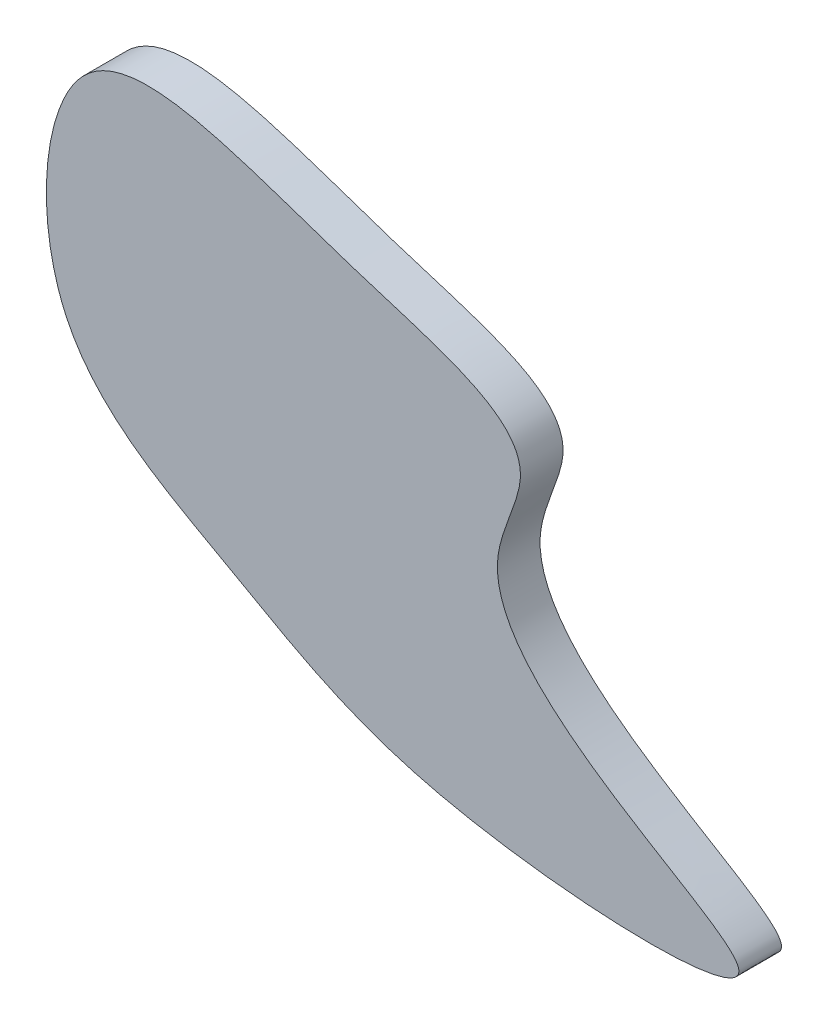
from build123d import *

# Parameters (mm, degrees)
AUFSATZ_LINEAR_AUSTRAGEN1_DEPTH = 10


with BuildPart() as part:
    # Skizze1 → Aufsatz-Linear austragen1 (new body)
    with BuildSketch(Plane.XY):
        with BuildLine():
            add(Edge.make_bspline(
                [(-80.538228006, 16.11258968), (-73.222394057, 0.474519064), (-39.773783933, -16.204726599), (0.660761159, -42.279815022), (127.962480816, -47.405838525), (3.664983183, -3.73898255), (35.35770239, 46.696284543), (-22.525997246, 60.021411727), (-83.548915587, 88.845318161), (-88.209584535, 32.510612923), (-80.538228006, 16.11258968)],
                knots=[0, 0, 0, 0, 0.112755714, 0.233476145, 0.401323458, 0.583683402, 0.629662187, 0.7307253, 0.881764774, 1, 1, 1, 1], degree=3))
        make_face()
    extrude(amount=AUFSATZ_LINEAR_AUSTRAGEN1_DEPTH)


solid = part.part
